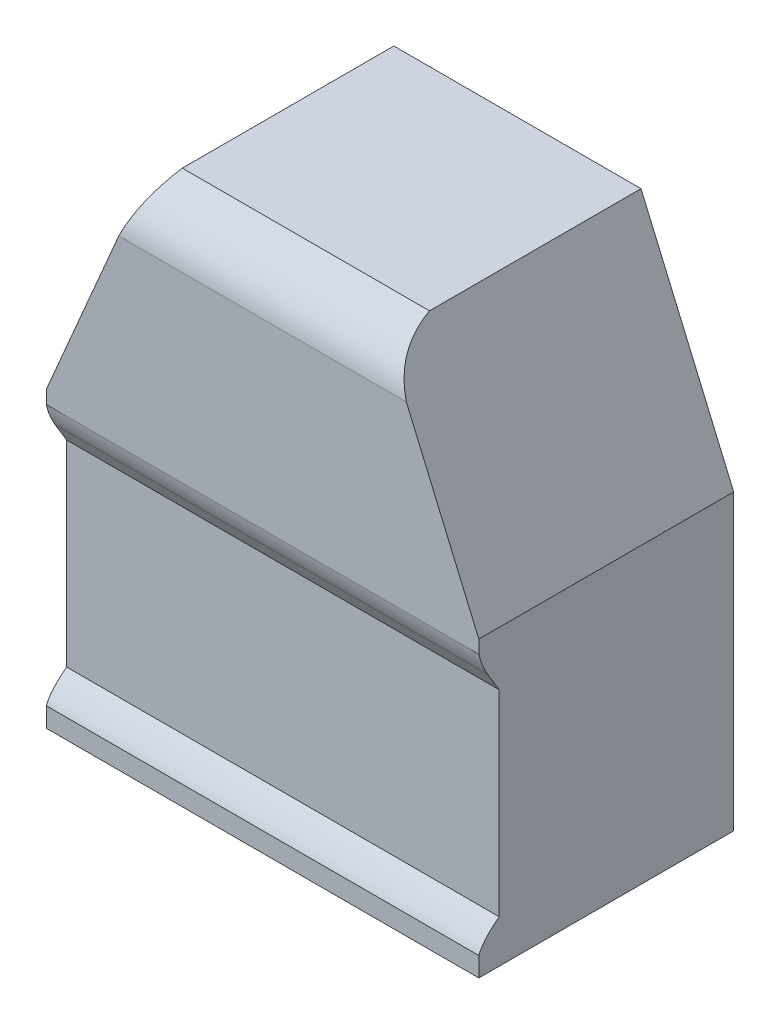
from build123d import *

# Parameters (mm, degrees)
BOSS_EXTRUDE1_DEPTH      = 100
BOSS_EXTRUDE1_DEPTH_BACK = 65
CUT_EXTRUDE1_DEPTH       = 280


with BuildPart() as part:
    # Sketch1 → Boss-Extrude1 (new body, two sides)
    with BuildSketch(Plane.XY) as boss_extrude1_sk:
        Polygon((-140, 95), (-140, -95), (140, -95), (140, 95), (80, 235), (-80, 235), align=None)
    extrude(amount=BOSS_EXTRUDE1_DEPTH)
    extrude(boss_extrude1_sk.sketch, amount=-BOSS_EXTRUDE1_DEPTH_BACK)

    # Sketch2 → Cut-Extrude1 (cut)
    with BuildSketch(Plane(origin=(140, 0, 0), x_dir=(0, 0, -1), z_dir=(1, 0, 0))):
        with BuildLine():
            Line((-100, 190.377151129), (-100, 104.513728645))
            add(Edge.make_bspline(
                [(-100, 104.513728645), (-102.224477009, 93.061564682), (-100.352557358, 82.398786726), (-94.384241048, 72.525394779)],
                knots=[0, 0, 0, 0, 1, 1, 1, 1], degree=3))
            Line((-94.384241048, 72.525394779), (-86.862061889, 60.08144589))
            Line((-86.862061889, 60.08144589), (-86.862061889, -67.213116322))
            add(Edge.make_bspline(
                [(-86.862061889, -67.213116322), (-95.040230762, -73.563203777), (-104.810422505, -83.101213531), (-100, -95)],
                knots=[0, 0, 0, 0, 1, 1, 1, 1], degree=3))
            Line((-100, -95), (-158.360908781, -95))
            Line((-158.360908781, -95), (-158.360908781, 235))
            Line((-158.360908781, 235), (-71.936287457, 235))
            add(Edge.make_bspline(
                [(-71.936287457, 235), (-104.052371602, 224.516044217), (-100, 190.377151129)],
                knots=[0, 0, 0, 1, 1, 1], degree=2))
        make_face()
    extrude(amount=-CUT_EXTRUDE1_DEPTH, mode=Mode.SUBTRACT)


solid = part.part
